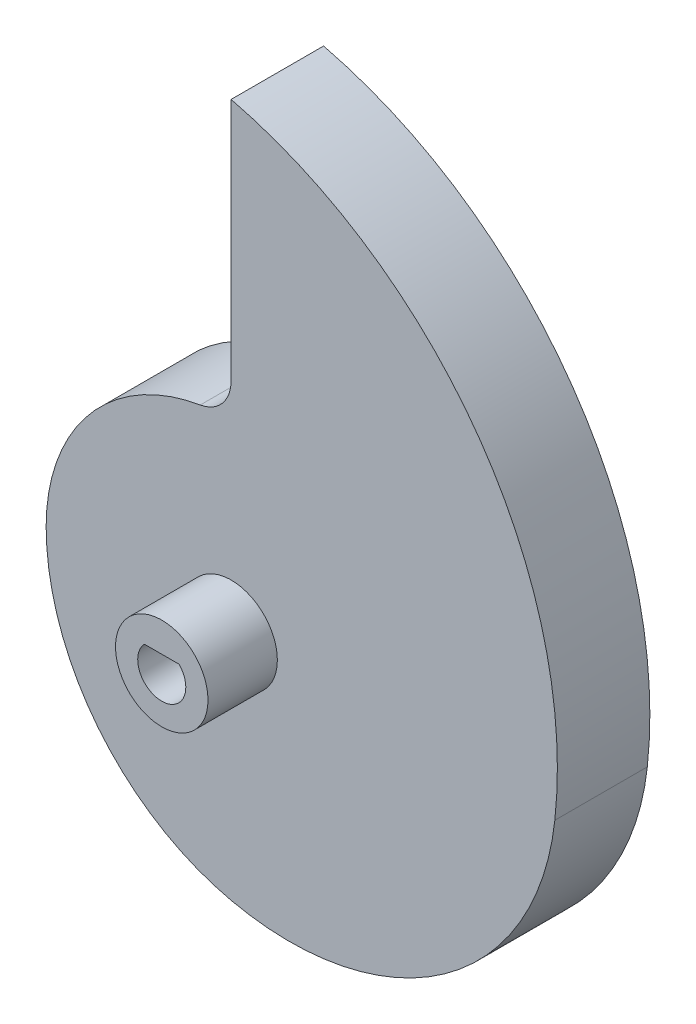
from build123d import *

# Parameters (mm, degrees)
BOSS_EXTRUDE1_DEPTH = 6.35
SKETCH2_R           = 3.175
BOSS_EXTRUDE2_DEPTH = 4.7625
CUT_EXTRUDE1_DEPTH  = 12.1125
FILLET1_R           = 2.54


with BuildPart() as part:
    # Sketch1 → Boss-Extrude1 (new body)
    with BuildSketch(Plane.XY):
        with BuildLine():
            ThreePointArc((0, -15.875), (14.664616841, -12.910463577), (22.225, 0))
            ThreePointArc((22.225, 0), (17.085257234, 20.055930064), (0, 31.75))
            Line((0, 31.75), (0, 0))
            Line((0, 0), (-12.7, 0))
            ThreePointArc((-12.7, 0), (-9.134324659, -10.164959727), (0, -15.875))
        make_face()
        with BuildLine():
            Line((-12.7, 0), (0, 0))
            Line((0, 0), (0, 12.7))
            ThreePointArc((0, 12.7), (-8.980256121, 8.980256121), (-12.7, 0))
        make_face()
    extrude(amount=BOSS_EXTRUDE1_DEPTH)

    # Sketch2 → Boss-Extrude2 (add)
    with BuildSketch(Plane.XY.offset(6.35)):
        Circle(SKETCH2_R)
    extrude(amount=BOSS_EXTRUDE2_DEPTH)

    # Sketch3 → Cut-Extrude1 (cut, through all)
    with BuildSketch(Plane.XY.offset(11.1125)):
        with BuildLine():
            Line((1.191365603, 1.143), (-1.191365603, 1.143))
            ThreePointArc((-1.191365603, 1.143), (-0.61597743, -1.531787454), (1.651, 0))
            ThreePointArc((1.651, 0), (1.531787454, 0.61597743), (1.191365603, 1.143))
        make_face()
    extrude(amount=-CUT_EXTRUDE1_DEPTH, mode=Mode.SUBTRACT)

    # Fillet1
    fillet1_edges = [part.edges().sort_by_distance(p)[0] for p in [
        (0, 12.7, 3.175),
    ]]
    fillet(fillet1_edges, radius=FILLET1_R)


solid = part.part
